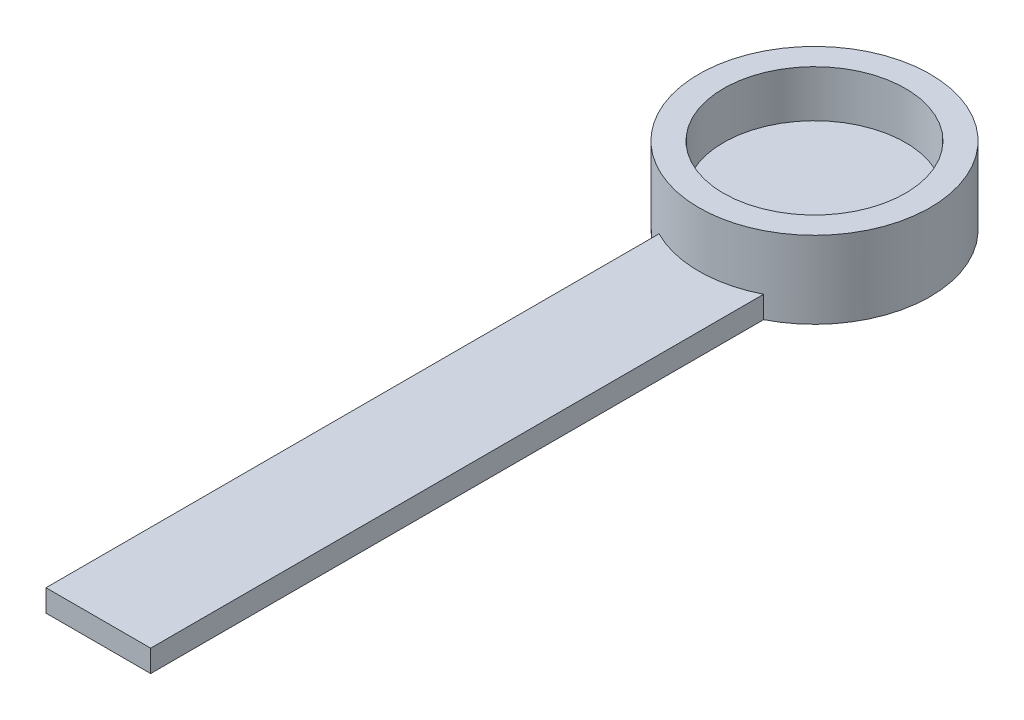
from build123d import *

# Parameters (mm, degrees)
F_0_1MM_FIT_FOR_POT_R = 10.5
BOSS_EXTRUDE1_DEPTH   = 2.75
SKETCH4_R             = 10.5
SKETCH4_R_2           = 8.25
BOSS_EXTRUDE2_DEPTH   = 4.25
BOSS_EXTRUDE3_DEPTH   = 2
FILLET1_R             = 0.25
BOSS_EXTRUDE4_DEPTH   = 2


with BuildPart() as part:
    # 0.1mm fit for pot → Boss-Extrude1 (new body)
    with BuildSketch(Plane(origin=(0, 0, 0), x_dir=(1, 0, 0), z_dir=(0, 1, 0))):
        Circle(F_0_1MM_FIT_FOR_POT_R)
    extrude(amount=BOSS_EXTRUDE1_DEPTH)

    # Sketch4 → Boss-Extrude2 (add)
    with BuildSketch(Plane(origin=(0, 2.75, 0), x_dir=(1, 0, 0), z_dir=(0, 1, 0))):
        Circle(SKETCH4_R)
        Circle(SKETCH4_R_2, mode=Mode.SUBTRACT)
    extrude(amount=BOSS_EXTRUDE2_DEPTH)

    # Sketch5 → Boss-Extrude3 (add)
    with BuildSketch(Plane(origin=(0, 2.75, 0), x_dir=(1, 0, 0), z_dir=(0, 1, 0))):
        with BuildLine():
            Line((-1, -8.189169677), (-1, -7.05))
            Line((-1, -7.05), (1, -7.05))
            Line((1, -7.05), (1, -8.189169677))
            ThreePointArc((1, -8.189169677), (0, -8.25), (-1, -8.189169677))
        make_face()
    extrude(amount=BOSS_EXTRUDE3_DEPTH)

    # Fillet1
    fillet1_edges = [part.edges().sort_by_distance(p)[0] for p in [
        (1, 3.75, 7.05),
        (-1, 3.75, 7.05),
        (0, 4.75, 7.05),
        (-1, 4.75, 7.619584839),
        (1, 4.75, 7.619584839),
    ]]
    fillet(fillet1_edges, radius=FILLET1_R)

    # Sketch6 → Boss-Extrude4 (add)
    with BuildSketch(Plane.XZ):
        with BuildLine():
            Line((-4.75, 9.3641604), (-4.75, 65))
            Line((-4.75, 65), (4.75, 65))
            Line((4.75, 65), (4.75, 9.3641604))
            ThreePointArc((4.75, 9.3641604), (0, 10.5), (-4.75, 9.3641604))
        make_face()
    extrude(amount=-BOSS_EXTRUDE4_DEPTH)


solid = part.part
